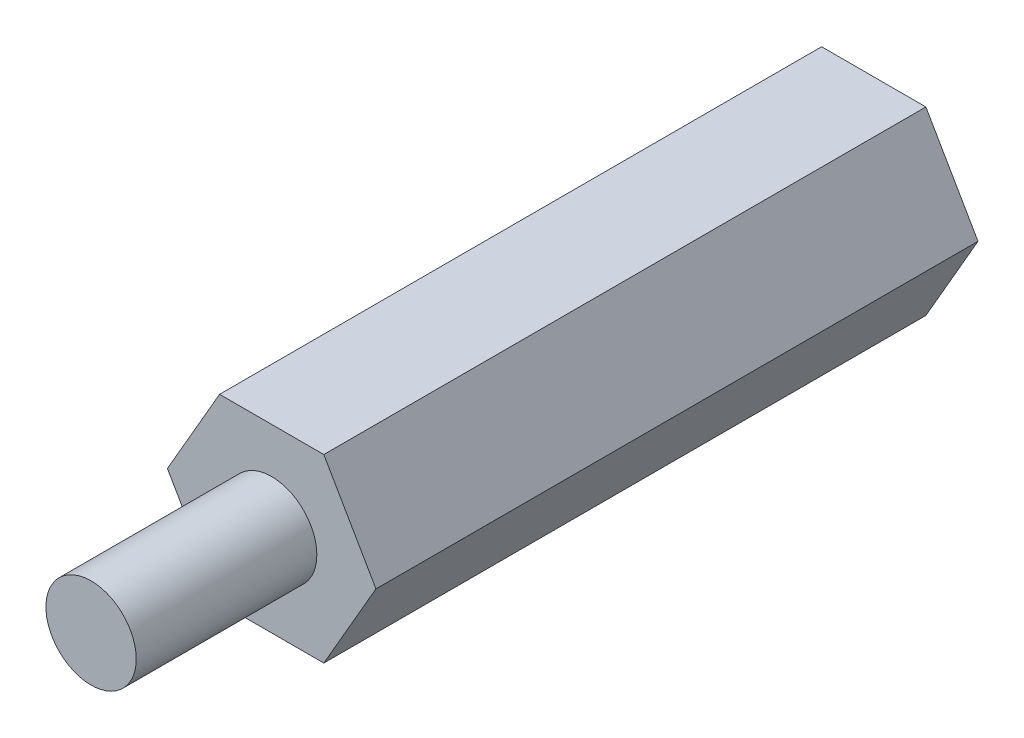
from build123d import *

# Parameters (mm, degrees)
BOSS_EXTRUDE1_DEPTH       = 20
SKETCH2_R                 = 1.5
BOSS_EXTRUDE2_DEPTH       = 6
M3X0_5_TAPPED_HOLE1_D     = 2.5
M3X0_5_TAPPED_HOLE1_DEPTH = 6
M3X0_5_TAPPED_HOLE1_TIP   = 0.751075774


with BuildPart() as part:
    # Sketch1 → Boss-Extrude1 (new body)
    with BuildSketch(Plane.XY):
        Polygon((-3.464101615, 0), (-1.732050808, -3), (1.732050808, -3), (3.464101615, 0), (1.732050808, 3), (-1.732050808, 3), align=None)
    extrude(amount=BOSS_EXTRUDE1_DEPTH)

    # Sketch2 → Boss-Extrude2 (add)
    with BuildSketch(Plane.XY.offset(20)):
        Circle(SKETCH2_R)
    extrude(amount=BOSS_EXTRUDE2_DEPTH)

    # M3x0.5 Tapped Hole1
    with Locations(Plane(origin=(0, 0, 0), x_dir=(-1, 0, 0), z_dir=(0, 0, -1))):
        with Locations((0, 0)):
            Hole(M3X0_5_TAPPED_HOLE1_D / 2, depth=M3X0_5_TAPPED_HOLE1_DEPTH)
            with Locations((0, 0, -(M3X0_5_TAPPED_HOLE1_DEPTH + M3X0_5_TAPPED_HOLE1_TIP / 2))):  # 118° drill point
                Cone(0, M3X0_5_TAPPED_HOLE1_D / 2, M3X0_5_TAPPED_HOLE1_TIP, mode=Mode.SUBTRACT)


solid = part.part
